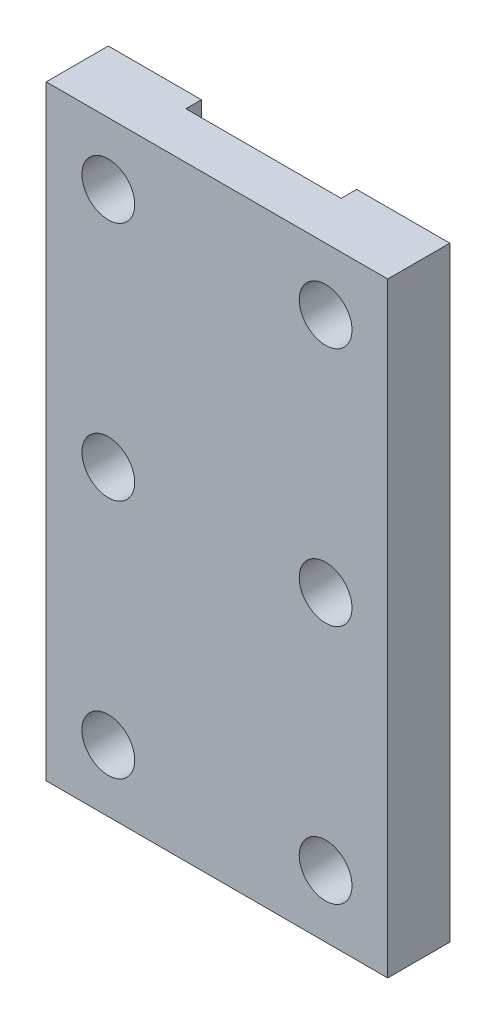
from build123d import *

# Parameters (mm, degrees)
SKETCH_1_W                  = 22
SKETCH_1_H                  = 39
EXTRUDE_1_DEPTH             = 4
SKETCH_2_W                  = 10
SKETCH_2_H                  = 1
CUT_EXTRUDE_1_DEPTH         = 40
SKETCH_3_R                  = 1.7
CUT_EXTRUDE_2_DEPTH         = 5
PATTERN_LINEAR_1_COUNT      = 2
PATTERN_LINEAR_1_PITCH      = 14
PATTERN_LINEAR_1_COUNT_DIR2 = 3
PATTERN_LINEAR_1_PITCH_DIR2 = 15.5


with BuildPart() as part:
    # 草圖1 → 填料-伸長1 (new body)
    with BuildSketch(Plane.XY):
        Rectangle(SKETCH_1_W, SKETCH_1_H)
    extrude(amount=EXTRUDE_1_DEPTH)

    # 草圖2 → 除料-伸長1 (cut, through all)
    with BuildSketch(Plane(origin=(0, 19.5, 0), x_dir=(1, 0, 0), z_dir=(0, 1, 0))):
        with Locations((0, -0.5)):
            Rectangle(SKETCH_2_W, SKETCH_2_H)
    extrude(amount=-CUT_EXTRUDE_1_DEPTH, mode=Mode.SUBTRACT)

    # 草圖3 → 除料-伸長2 (cut, through all)
    with BuildSketch(Plane(origin=(0, 0, 0), x_dir=(-1, 0, 0), z_dir=(0, 0, -1))):
        with Locations((-7, 15.5)):
            Circle(SKETCH_3_R)
    cut_extrude_2 = extrude(amount=-CUT_EXTRUDE_2_DEPTH, mode=Mode.SUBTRACT)

    # 直線複製排列1: Cut-Extrude 2 2 × 3
    with Locations(*[(-i * PATTERN_LINEAR_1_PITCH, -j * PATTERN_LINEAR_1_PITCH_DIR2, 0) for i in range(PATTERN_LINEAR_1_COUNT) for j in range(PATTERN_LINEAR_1_COUNT_DIR2) if (i, j) != (0, 0)]):
        add(cut_extrude_2, mode=Mode.SUBTRACT)


solid = part.part
